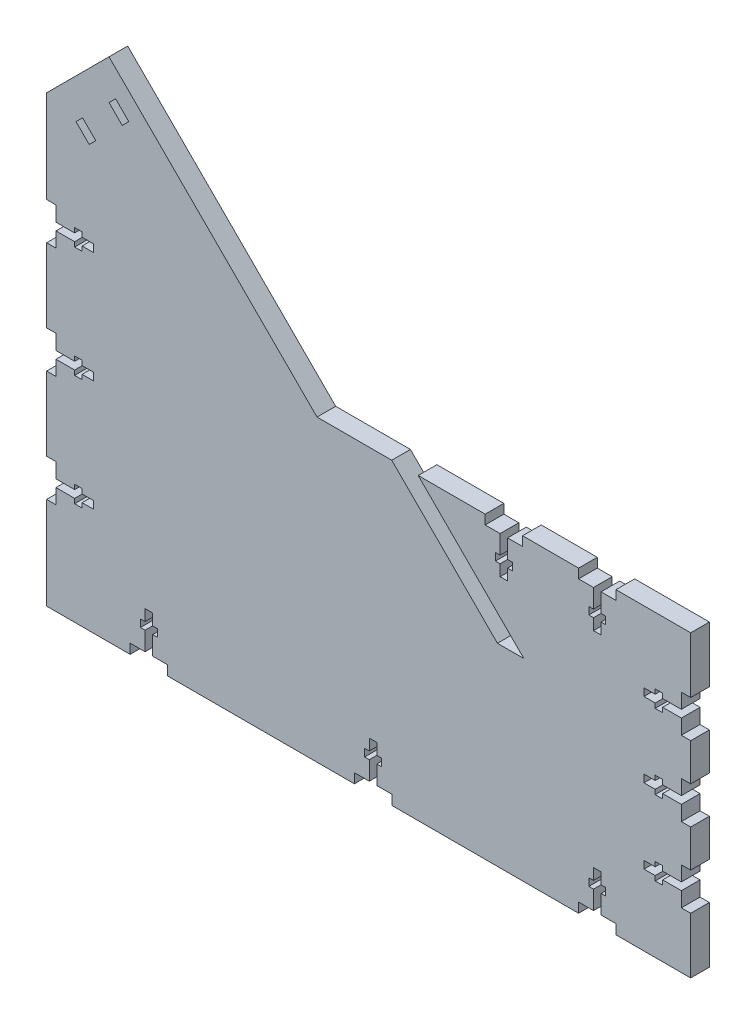
from build123d import *

# Parameters (mm, degrees)
BOSS_EXTRUDE1_DEPTH     = 6.35
CUT_EXTRUDE2_DEPTH      = 2.54
CUT_EXTRUDE2_DEPTH_BACK = 127
CUT_EXTRUDE4_DEPTH      = 127
CUT_EXTRUDE4_DEPTH_BACK = 127
CUT_EXTRUDE5_DEPTH      = 127
CUT_EXTRUDE5_DEPTH_BACK = 127


with BuildPart() as part:
    # Sketch1 → Boss-Extrude1 (new body)
    with BuildSketch(Plane.XY):
        Polygon((0, 0), (127, 0), (127, 101.6), (0, 101.6), (-70.692427737, 172.292427737), (-91.896861793, 151.087993682), (-91.896861793, 0), align=None)
    extrude(amount=BOSS_EXTRUDE1_DEPTH)

    # Sketch2 → Cut-Extrude2 (cut, two sides: drawn at the far end of the back side and taken through both)
    with BuildSketch(Plane(origin=(0, 0, 0), x_dir=(-1, 0, 0), z_dir=(0, 0, -1)).offset(-CUT_EXTRUDE2_DEPTH_BACK)):
        Polygon((-61.321024484, 65.678975516), (-25.4, 101.6), (-34.380256106, 101.6), (-52.340768348, 83.639487758), (-70.30128059, 65.678975516), align=None)
    extrude(amount=CUT_EXTRUDE2_DEPTH + CUT_EXTRUDE2_DEPTH_BACK, mode=Mode.SUBTRACT)

    # Sketch3 → Cut-Extrude4 (cut, two sides: drawn at the far end of the back side and taken through both)
    with BuildSketch(Plane(origin=(0, 0, 0), x_dir=(-1, 0, 0), z_dir=(0, 0, -1)).offset(-CUT_EXTRUDE4_DEPTH_BACK)):
        Polygon((68.447363707, 161.067107586), (63.957235647, 156.576979525), (66.202299677, 154.331915495), (70.692427737, 158.822043556), align=None)
        Polygon((-127, 31.75), (-127, 19.05), (-123.825, 19.05), (-123.825, 24.1173), (-117.475, 24.1173), (-117.475, 22.5298), (-114.935, 22.5298), (-114.935, 24.1173), (-111.125, 24.1173), (-111.125, 26.6827), (-114.935, 26.6827), (-114.935, 28.2702), (-117.475, 28.2702), (-117.475, 26.6827), (-123.825, 26.6827), (-123.825, 31.75), align=None)
        Polygon((-57.15, 101.6), (-69.85, 101.6), (-69.85, 98.425), (-64.77, 98.425), (-64.77, 92.075), (-66.3575, 92.075), (-66.3575, 89.535), (-64.77, 89.535), (-64.77, 85.725), (-62.23, 85.725), (-62.23, 89.535), (-60.6425, 89.535), (-60.6425, 92.075), (-62.23, 92.075), (-62.23, 98.425), (-57.15, 98.425), align=None)
        Polygon((-88.9, 101.6), (-101.6, 101.6), (-101.6, 98.425), (-96.5327, 98.425), (-96.5327, 92.075), (-98.1202, 92.075), (-98.1202, 89.535), (-96.5327, 89.535), (-96.5327, 85.725), (-93.9673, 85.725), (-93.9673, 89.535), (-92.3798, 89.535), (-92.3798, 92.075), (-93.9673, 92.075), (-93.9673, 98.425), (-88.9, 98.425), align=None)
        Polygon((-127, 82.55), (-127, 69.85), (-123.825, 69.85), (-123.825, 74.9173), (-117.475, 74.9173), (-117.475, 73.3298), (-114.935, 73.3298), (-114.935, 74.9173), (-111.125, 74.9173), (-111.125, 77.4827), (-114.935, 77.4827), (-114.935, 79.0702), (-117.475, 79.0702), (-117.475, 77.4827), (-123.825, 77.4827), (-123.825, 82.55), align=None)
        Polygon((-127, 57.15), (-127, 44.45), (-123.825, 44.45), (-123.825, 49.5173), (-117.475, 49.5173), (-117.475, 47.9298), (-114.935, 47.9298), (-114.935, 49.5173), (-111.125, 49.5173), (-111.125, 52.0827), (-114.935, 52.0827), (-114.935, 53.6702), (-117.475, 53.6702), (-117.475, 52.0827), (-123.825, 52.0827), (-123.825, 57.15), align=None)
        Polygon((88.721861793, 106.965995261), (91.896861793, 106.965995261), (91.896861793, 119.665995261), (88.721861793, 119.665995261), (88.721861793, 114.598695261), (82.371861793, 114.598695261), (82.371861793, 116.186195261), (79.831861793, 116.186195261), (79.831861793, 114.598695261), (76.021861793, 114.598695261), (76.021861793, 112.033295261), (79.831861793, 112.033295261), (79.831861793, 110.445795261), (82.371861793, 110.445795261), (82.371861793, 112.033295261), (88.721861793, 112.033295261), align=None)
        Polygon((88.721861793, 69.193996841), (91.896861793, 69.193996841), (91.896861793, 81.893996841), (88.721861793, 81.893996841), (88.721861793, 76.826696841), (82.371861793, 76.826696841), (82.371861793, 78.414196841), (79.831861793, 78.414196841), (79.831861793, 76.826696841), (76.021861793, 76.826696841), (76.021861793, 74.261296841), (79.831861793, 74.261296841), (79.831861793, 72.673796841), (82.371861793, 72.673796841), (82.371861793, 74.261296841), (88.721861793, 74.261296841), align=None)
        Polygon((88.721861793, 31.42199842), (91.896861793, 31.42199842), (91.896861793, 44.12199842), (88.721861793, 44.12199842), (88.721861793, 39.05469842), (82.371861793, 39.05469842), (82.371861793, 40.64219842), (79.831861793, 40.64219842), (79.831861793, 39.05469842), (76.021861793, 39.05469842), (76.021861793, 36.48929842), (79.831861793, 36.48929842), (79.831861793, 34.90179842), (82.371861793, 34.90179842), (82.371861793, 36.48929842), (88.721861793, 36.48929842), align=None)
        Polygon((50.8, 3.302), (50.8, 0), (63.5, 0), (63.5, 3.302), (58.4327, 3.302), (58.4327, 9.652), (60.0202, 9.652), (60.0202, 12.192), (58.4327, 12.192), (58.4327, 16.002), (55.8673, 16.002), (55.8673, 12.192), (54.2798, 12.192), (54.2798, 9.652), (55.8673, 9.652), (55.8673, 3.302), align=None)
        Polygon((-25.4, 3.302), (-25.4, 0), (-12.7, 0), (-12.7, 3.302), (-17.7673, 3.302), (-17.7673, 9.652), (-16.1798, 9.652), (-16.1798, 12.192), (-17.7673, 12.192), (-17.7673, 16.002), (-20.3327, 16.002), (-20.3327, 12.192), (-21.9202, 12.192), (-21.9202, 9.652), (-20.3327, 9.652), (-20.3327, 3.302), align=None)
        Polygon((-101.6, 3.302), (-101.6, 0), (-88.9, 0), (-88.9, 3.302), (-93.9673, 3.302), (-93.9673, 9.652), (-92.3798, 9.652), (-92.3798, 12.192), (-93.9673, 12.192), (-93.9673, 16.002), (-96.5327, 16.002), (-96.5327, 12.192), (-98.1202, 12.192), (-98.1202, 9.652), (-96.5327, 9.652), (-96.5327, 3.302), align=None)
    extrude(amount=CUT_EXTRUDE4_DEPTH + CUT_EXTRUDE4_DEPTH_BACK, mode=Mode.SUBTRACT)

    # Sketch4 → Cut-Extrude5 (cut, two sides: drawn at the far end of the back side and taken through both)
    with BuildSketch(Plane.XY.offset(-CUT_EXTRUDE5_DEPTH_BACK)):
        Polygon((-81.917747889, 147.596723404), (-79.672683858, 149.841787435), (-75.182555798, 145.351659374), (-77.427619828, 143.106595344), align=None)
    extrude(amount=CUT_EXTRUDE5_DEPTH + CUT_EXTRUDE5_DEPTH_BACK, mode=Mode.SUBTRACT)


solid = part.part
